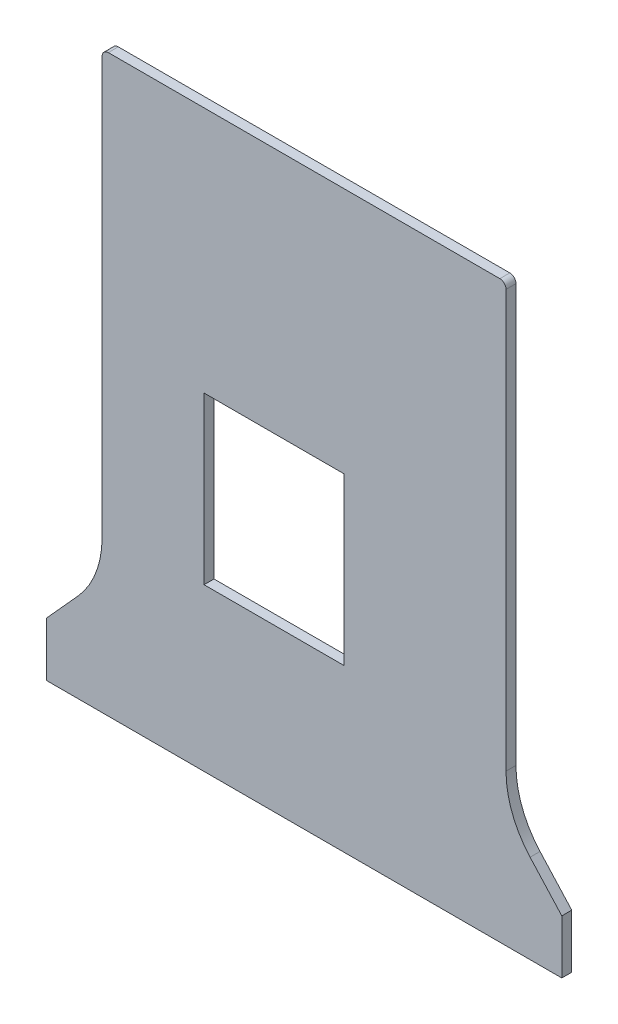
from build123d import *

# Parameters (mm, degrees)
BOARD_W             = 22.5
BOARD_H             = 26.72
BOSS_EXTRUDE2_DEPTH = 1.6


with BuildPart() as part:
    # BOARD → Boss-Extrude2 (new body)
    with BuildSketch(Plane.XY):
        with BuildLine():
            Line((78.158087673, 14.315192257), (83.26046847, 8.69))
            Line((83.26046847, 8.69), (83.26046847, 0.03))
            Line((83.26046847, 0.03), (0.28, 0.03))
            Line((0.28, 0.03), (0.28, 8.69))
            Line((0.28, 8.69), (5.37370372, 14.323050696))
            ThreePointArc((5.37370372, 14.323050696), (8.254635545, 18.990143234), (9.27, 24.38))
            Line((9.27, 24.38), (9.27, 91.540000744))
            ThreePointArc((9.27, 91.540000744), (9.567594313, 92.239511842), (10.270147398, 92.529851835))
            Line((10.270147398, 92.529851835), (73.290147398, 92.529851835))
            ThreePointArc((73.290147398, 92.529851835), (73.989702799, 92.232361682), (74.280147398, 91.529851835))
            Line((74.280147398, 91.529851835), (74.280147398, 24.369851835))
            ThreePointArc((74.280147398, 24.369851835), (75.287357034, 18.983155173), (78.158087673, 14.315192257))
        make_face()
        with Locations((36.93, 39.42)):
            Rectangle(BOARD_W, BOARD_H, mode=Mode.SUBTRACT)
    extrude(amount=BOSS_EXTRUDE2_DEPTH)


solid = part.part
